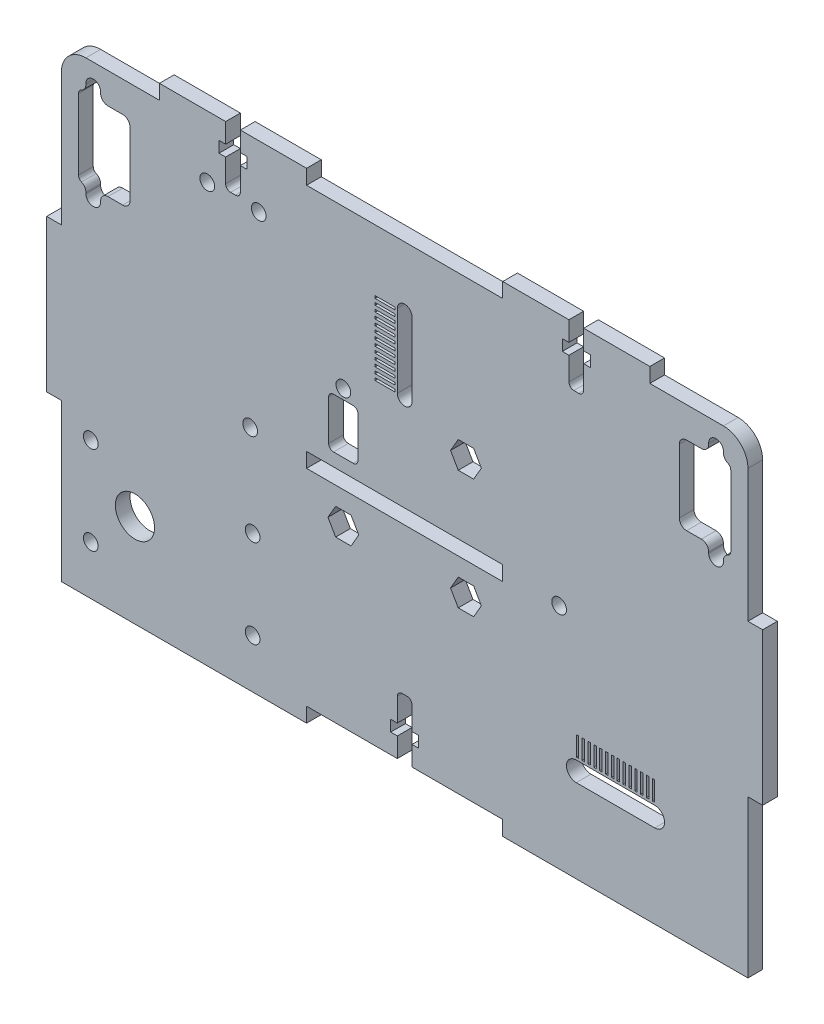
from build123d import *

# Parameters (mm, degrees)
ESBO_O1_W                   = 140
ESBO_O1_H                   = 95
RESSALTO_EXTRUS_O1_DEPTH    = 1.5
ESBO_O2_R                   = 1.5
ESBO_O2_W                   = 40
ESBO_O2_H                   = 3
CORTE_EXTRUS_O1_DEPTH       = 4
CUT_EXTRUDE12_DEPTH         = 2.5
CUT_EXTRUDE12_DEPTH_BACK    = 2.5
ESBO_O3_W                   = 3
ESBO_O3_H                   = 31
ESBO_O3_W_2                 = 30
ESBO_O3_H_2                 = 3
RESSALTO_EXTRUS_O2_DEPTH    = 3
ESBO_O30_R                  = 4
CORTE_EXTRUS_O11_DEPTH      = 1
CORTE_EXTRUS_O11_DEPTH_BACK = 4
ESBO_O4_W                   = 0.5
ESBO_O4_H                   = 4
CORTE_EXTRUS_O2_DEPTH       = 4
ESBO_O31_R                  = 1.5
CORTE_EXTRUS_O12_DEPTH      = 1
CORTE_EXTRUS_O12_DEPTH_BACK = 4
CUT_EXTRUDE11_DEPTH         = 1
CUT_EXTRUDE11_DEPTH_BACK    = 4
CUT_EXTRUDE14_DEPTH         = 2.5
CUT_EXTRUDE14_DEPTH_BACK    = 2.5
SKETCH12_W                  = 4
SKETCH12_H                  = 0.5
CUT_EXTRUDE15_DEPTH         = 4
SKETCH13_R                  = 1.5
CUT_EXTRUDE16_DEPTH         = 2.5
CUT_EXTRUDE16_DEPTH_BACK    = 2.5
FILLET1_R                   = 5
SKETCH14_R                  = 1.5
CUT_EXTRUDE17_DEPTH         = 2.5
CUT_EXTRUDE17_DEPTH_BACK    = 2.5


with BuildPart() as part:
    # Esboço1 → Ressalto-extrusão1 (new body, symmetric)
    with BuildSketch(Plane.XY):
        Rectangle(ESBO_O1_W, ESBO_O1_H)
    extrude(amount=RESSALTO_EXTRUS_O1_DEPTH, both=True)

    # Esboço2 → Corte-extrusão1 (cut, through all)
    with BuildSketch(Plane.XY.offset(1.5)):
        with Locations((-31.5, -1)):
            Circle(ESBO_O2_R)
        with Locations((31.5, -1)):
            Circle(ESBO_O2_R)
        with Locations((0, -46)):
            Rectangle(ESBO_O2_W, ESBO_O2_H)
        with Locations((0, -1)):
            Rectangle(ESBO_O2_W, ESBO_O2_H)
    extrude(amount=-CORTE_EXTRUS_O1_DEPTH, mode=Mode.SUBTRACT)

    # Sketch9 → Cut-Extrude12 (cut, two sides)
    with BuildSketch(Plane.XY) as cut_extrude12_sk:
        with BuildLine():
            Line((-1.5, -44.5), (1.5, -44.5))
            Line((1.5, -44.5), (1.5, -40.5))
            Line((1.5, -40.5), (2.85, -40.5))
            Line((2.85, -40.5), (2.85, -38.23))
            Line((2.85, -38.23), (1.5, -38.23))
            Line((1.5, -38.23), (1.5, -33.5))
            ThreePointArc((1.5, -33.5), (1.207106781, -32.792893219), (0.5, -32.5))
            Line((0.5, -32.5), (-0.5, -32.5))
            ThreePointArc((-0.5, -32.5), (-1.207106781, -32.792893219), (-1.5, -33.5))
            Line((-1.5, -33.5), (-1.5, -38.23))
            Line((-1.5, -38.23), (-2.85, -38.23))
            Line((-2.85, -38.23), (-2.85, -40.5))
            Line((-2.85, -40.5), (-1.5, -40.5))
            Line((-1.5, -40.5), (-1.5, -44.5))
        make_face()
    extrude(amount=CUT_EXTRUDE12_DEPTH, mode=Mode.SUBTRACT)
    extrude(cut_extrude12_sk.sketch, amount=-CUT_EXTRUDE12_DEPTH_BACK, mode=Mode.SUBTRACT)

    # Esboço3 → Ressalto-extrusão2 (add, through all)
    with BuildSketch(Plane.XY.offset(1.5)):
        with Locations((71.5, 0)):
            Rectangle(ESBO_O3_W, ESBO_O3_H)
        with Locations((-71.5, 0)):
            Rectangle(ESBO_O3_W, ESBO_O3_H)
        with Locations((-35, 49)):
            Rectangle(ESBO_O3_W_2, ESBO_O3_H_2)
        with Locations((35, 49)):
            Rectangle(ESBO_O3_W_2, ESBO_O3_H_2)
    extrude(amount=-RESSALTO_EXTRUS_O2_DEPTH)

    # Esboço30 → Corte-extrusão11 (cut, two sides)
    with BuildSketch(Plane(origin=(0, 0, -1.5), x_dir=(-1, 0, 0), z_dir=(0, 0, -1))) as corte_extrus_o11_sk:
        with Locations((55, -28.5)):
            Circle(ESBO_O30_R)
    extrude(amount=CORTE_EXTRUS_O11_DEPTH, mode=Mode.SUBTRACT)
    extrude(corte_extrus_o11_sk.sketch, amount=-CORTE_EXTRUS_O11_DEPTH_BACK, mode=Mode.SUBTRACT)

    # Esboço4 → Corte-extrusão2 (cut, through all)
    with BuildSketch(Plane.XY.offset(1.5)):
        with BuildLine():
            Line((35, -26.5), (51, -26.5))
            ThreePointArc((51, -26.5), (53, -28.5), (51, -30.5))
            Line((51, -30.5), (35, -30.5))
            ThreePointArc((35, -30.5), (33, -28.5), (35, -26.5))
        make_face()
        with Locations((35.25, -24)):
            Rectangle(ESBO_O4_W, ESBO_O4_H)
        with Locations((36.442307692, -24)):
            Rectangle(ESBO_O4_W, ESBO_O4_H)
        with Locations((37.634615385, -24)):
            Rectangle(ESBO_O4_W, ESBO_O4_H)
        with Locations((38.826923077, -24)):
            Rectangle(ESBO_O4_W, ESBO_O4_H)
        with Locations((40.019230769, -24)):
            Rectangle(ESBO_O4_W, ESBO_O4_H)
        with Locations((41.211538462, -24)):
            Rectangle(ESBO_O4_W, ESBO_O4_H)
        with Locations((42.403846154, -24)):
            Rectangle(ESBO_O4_W, ESBO_O4_H)
        with Locations((43.596153846, -24)):
            Rectangle(ESBO_O4_W, ESBO_O4_H)
        with Locations((44.788461538, -24)):
            Rectangle(ESBO_O4_W, ESBO_O4_H)
        with Locations((45.980769231, -24)):
            Rectangle(ESBO_O4_W, ESBO_O4_H)
        with Locations((47.173076923, -24)):
            Rectangle(ESBO_O4_W, ESBO_O4_H)
        with Locations((48.365384615, -24)):
            Rectangle(ESBO_O4_W, ESBO_O4_H)
        with Locations((49.557692308, -24)):
            Rectangle(ESBO_O4_W, ESBO_O4_H)
        with Locations((50.75, -24)):
            Rectangle(ESBO_O4_W, ESBO_O4_H)
    extrude(amount=-CORTE_EXTRUS_O2_DEPTH, mode=Mode.SUBTRACT)

    # Esboço31 → Corte-extrusão12 (cut, two sides)
    with BuildSketch(Plane(origin=(0, 0, -1.5), x_dir=(-1, 0, 0), z_dir=(0, 0, -1))) as corte_extrus_o12_sk:
        with Locations((64, -19.5)):
            Circle(ESBO_O31_R)
        with Locations((64, -37.5)):
            Circle(ESBO_O31_R)
        with Locations((31, -19.5)):
            Circle(ESBO_O31_R)
        with Locations((31, -37.5)):
            Circle(ESBO_O31_R)
    extrude(amount=CORTE_EXTRUS_O12_DEPTH, mode=Mode.SUBTRACT)
    extrude(corte_extrus_o12_sk.sketch, amount=-CORTE_EXTRUS_O12_DEPTH_BACK, mode=Mode.SUBTRACT)

    # Sketch8 → Cut-Extrude11 (cut, two sides)
    with BuildSketch(Plane(origin=(0, 0, -1.5), x_dir=(-1, 0, 0), z_dir=(0, 0, -1))) as cut_extrude11_sk:
        with BuildLine():
            Line((-56, 39.75), (-56, 26.75))
            ThreePointArc((-56, 26.75), (-56.439339828, 25.689339828), (-57.5, 25.25))
            Line((-57.5, 25.25), (-60.5, 25.25))
            ThreePointArc((-60.5, 25.25), (-61.560660172, 24.810660172), (-62, 23.75))
            Line((-62, 23.75), (-62, 23.5))
            ThreePointArc((-62, 23.5), (-63.5, 22), (-65, 23.5))
            Line((-65, 23.5), (-65, 23.75))
            ThreePointArc((-65, 23.75), (-65.24500996, 24.571583836), (-65.9, 25.124772708))
            ThreePointArc((-65.9, 25.124772708), (-66.336660027, 25.49356529), (-66.5, 26.041287847))
            Line((-66.5, 26.041287847), (-66.5, 40.458712153))
            ThreePointArc((-66.5, 40.458712153), (-66.336660027, 41.00643471), (-65.9, 41.375227292))
            ThreePointArc((-65.9, 41.375227292), (-65.24500996, 41.928416164), (-65, 42.75))
            Line((-65, 42.75), (-65, 43))
            ThreePointArc((-65, 43), (-63.5, 44.5), (-62, 43))
            Line((-62, 43), (-62, 42.75))
            ThreePointArc((-62, 42.75), (-61.560660172, 41.689339828), (-60.5, 41.25))
            Line((-60.5, 41.25), (-57.5, 41.25))
            ThreePointArc((-57.5, 41.25), (-56.439339828, 40.810660172), (-56, 39.75))
        make_face()
        with BuildLine():
            Line((56, 39.75), (56, 26.75))
            ThreePointArc((56, 26.75), (56.439339828, 25.689339828), (57.5, 25.25))
            Line((57.5, 25.25), (60.5, 25.25))
            ThreePointArc((60.5, 25.25), (61.560660172, 24.810660172), (62, 23.75))
            Line((62, 23.75), (62, 23.5))
            ThreePointArc((62, 23.5), (63.5, 22), (65, 23.5))
            Line((65, 23.5), (65, 23.75))
            ThreePointArc((65, 23.75), (65.24500996, 24.571583836), (65.9, 25.124772708))
            ThreePointArc((65.9, 25.124772708), (66.336660027, 25.49356529), (66.5, 26.041287847))
            Line((66.5, 26.041287847), (66.5, 40.458712153))
            ThreePointArc((66.5, 40.458712153), (66.336660027, 41.00643471), (65.9, 41.375227292))
            ThreePointArc((65.9, 41.375227292), (65.24500996, 41.928416164), (65, 42.75))
            Line((65, 42.75), (65, 43))
            ThreePointArc((65, 43), (63.5, 44.5), (62, 43))
            Line((62, 43), (62, 42.75))
            ThreePointArc((62, 42.75), (61.560660172, 41.689339828), (60.5, 41.25))
            Line((60.5, 41.25), (57.5, 41.25))
            ThreePointArc((57.5, 41.25), (56.439339828, 40.810660172), (56, 39.75))
        make_face()
    extrude(amount=CUT_EXTRUDE11_DEPTH, mode=Mode.SUBTRACT)
    extrude(cut_extrude11_sk.sketch, amount=-CUT_EXTRUDE11_DEPTH_BACK, mode=Mode.SUBTRACT)

    # Sketch11 → Cut-Extrude14 (cut, two sides)
    with BuildSketch(Plane.XY) as cut_extrude14_sk:
        with BuildLine():
            Line((33.5, 50.5), (36.5, 50.5))
            Line((36.5, 50.5), (36.5, 46.5))
            Line((36.5, 46.5), (37.85, 46.5))
            Line((37.85, 46.5), (37.85, 44.23))
            Line((37.85, 44.23), (36.5, 44.23))
            Line((36.5, 44.23), (36.5, 39.5))
            ThreePointArc((36.5, 39.5), (36.207106781, 38.792893219), (35.5, 38.5))
            Line((35.5, 38.5), (34.5, 38.5))
            ThreePointArc((34.5, 38.5), (33.792893219, 38.792893219), (33.5, 39.5))
            Line((33.5, 39.5), (33.5, 44.23))
            Line((33.5, 44.23), (32.15, 44.23))
            Line((32.15, 44.23), (32.15, 46.5))
            Line((32.15, 46.5), (33.5, 46.5))
            Line((33.5, 46.5), (33.5, 50.5))
        make_face()
        with BuildLine():
            Line((-36.5, 44.23), (-37.85, 44.23))
            Line((-37.85, 44.23), (-37.85, 46.5))
            Line((-37.85, 46.5), (-36.5, 46.5))
            Line((-36.5, 46.5), (-36.5, 50.5))
            Line((-36.5, 50.5), (-33.5, 50.5))
            Line((-33.5, 50.5), (-33.5, 46.5))
            Line((-33.5, 46.5), (-32.15, 46.5))
            Line((-32.15, 46.5), (-32.15, 44.23))
            Line((-32.15, 44.23), (-33.5, 44.23))
            Line((-33.5, 44.23), (-33.5, 39.5))
            ThreePointArc((-33.5, 39.5), (-33.792893219, 38.792893219), (-34.5, 38.5))
            Line((-34.5, 38.5), (-35.5, 38.5))
            ThreePointArc((-35.5, 38.5), (-36.207106781, 38.792893219), (-36.5, 39.5))
            Line((-36.5, 39.5), (-36.5, 44.23))
        make_face()
    extrude(amount=CUT_EXTRUDE14_DEPTH, mode=Mode.SUBTRACT)
    extrude(cut_extrude14_sk.sketch, amount=-CUT_EXTRUDE14_DEPTH_BACK, mode=Mode.SUBTRACT)

    # Sketch12 → Cut-Extrude15 (cut, through all)
    with BuildSketch(Plane.XY.offset(1.5)):
        with BuildLine():
            Line((-1.5, 20), (-1.5, 35))
            ThreePointArc((-1.5, 35), (0, 36.5), (1.5, 35))
            Line((1.5, 35), (1.5, 20))
            ThreePointArc((1.5, 20), (0, 18.5), (-1.5, 20))
        make_face()
        with Locations((-4, 21.458333333)):
            Rectangle(SKETCH12_W, SKETCH12_H)
        with Locations((-4, 20.25)):
            Rectangle(SKETCH12_W, SKETCH12_H)
        with Locations((-4, 22.666666667)):
            Rectangle(SKETCH12_W, SKETCH12_H)
        with Locations((-4, 23.875)):
            Rectangle(SKETCH12_W, SKETCH12_H)
        with Locations((-4, 25.083333333)):
            Rectangle(SKETCH12_W, SKETCH12_H)
        with Locations((-4, 26.291666667)):
            Rectangle(SKETCH12_W, SKETCH12_H)
        with Locations((-4, 27.5)):
            Rectangle(SKETCH12_W, SKETCH12_H)
        with Locations((-4, 28.708333333)):
            Rectangle(SKETCH12_W, SKETCH12_H)
        with Locations((-4, 29.916666667)):
            Rectangle(SKETCH12_W, SKETCH12_H)
        with Locations((-4, 31.125)):
            Rectangle(SKETCH12_W, SKETCH12_H)
        with Locations((-4, 32.333333333)):
            Rectangle(SKETCH12_W, SKETCH12_H)
        with Locations((-4, 33.541666667)):
            Rectangle(SKETCH12_W, SKETCH12_H)
        with Locations((-4, 34.75)):
            Rectangle(SKETCH12_W, SKETCH12_H)
    extrude(amount=-CUT_EXTRUDE15_DEPTH, mode=Mode.SUBTRACT)

    # Sketch13 → Cut-Extrude16 (cut, two sides)
    with BuildSketch(Plane.XY) as cut_extrude16_sk:
        with Locations((-12.5, 15.35)):
            Circle(SKETCH13_R)
        with BuildLine():
            Line((-10.5, 13.35), (-14.5, 13.35))
            ThreePointArc((-14.5, 13.35), (-15.207106781, 13.057106781), (-15.5, 12.35))
            Line((-15.5, 12.35), (-15.5, 4.15))
            ThreePointArc((-15.5, 4.15), (-15.207106781, 3.442893219), (-14.5, 3.15))
            Line((-14.5, 3.15), (-10.5, 3.15))
            ThreePointArc((-10.5, 3.15), (-9.792893219, 3.442893219), (-9.5, 4.15))
            Line((-9.5, 4.15), (-9.5, 12.35))
            ThreePointArc((-9.5, 12.35), (-9.792893219, 13.057106781), (-10.5, 13.35))
        make_face()
        Polygon((15.64, 15.35), (14.07, 18.069319768), (10.93, 18.069319768), (9.36, 15.35), (10.93, 12.630680232), (14.07, 12.630680232), align=None)
        Polygon((15.64, -8.95), (14.07, -6.230680232), (10.93, -6.230680232), (9.36, -8.95), (10.93, -11.669319768), (14.07, -11.669319768), align=None)
        Polygon((-9.36, -8.95), (-10.93, -6.230680232), (-14.07, -6.230680232), (-15.64, -8.95), (-14.07, -11.669319768), (-10.93, -11.669319768), align=None)
    extrude(amount=CUT_EXTRUDE16_DEPTH, mode=Mode.SUBTRACT)
    extrude(cut_extrude16_sk.sketch, amount=-CUT_EXTRUDE16_DEPTH_BACK, mode=Mode.SUBTRACT)

    # Fillet1
    fillet1_edges = [part.edges().sort_by_distance(p)[0] for p in [
        (-70, 47.5, 0),
        (70, 47.5, 0),
    ]]
    fillet(fillet1_edges, radius=FILLET1_R)

    # Sketch14 → Cut-Extrude17 (cut, two sides)
    with BuildSketch(Plane.XY) as cut_extrude17_sk:
        with Locations((-29.75, 37.9)):
            Circle(SKETCH14_R)
        with Locations((-40.25, 37.9)):
            Circle(SKETCH14_R)
    extrude(amount=CUT_EXTRUDE17_DEPTH, mode=Mode.SUBTRACT)
    extrude(cut_extrude17_sk.sketch, amount=-CUT_EXTRUDE17_DEPTH_BACK, mode=Mode.SUBTRACT)


solid = part.part
